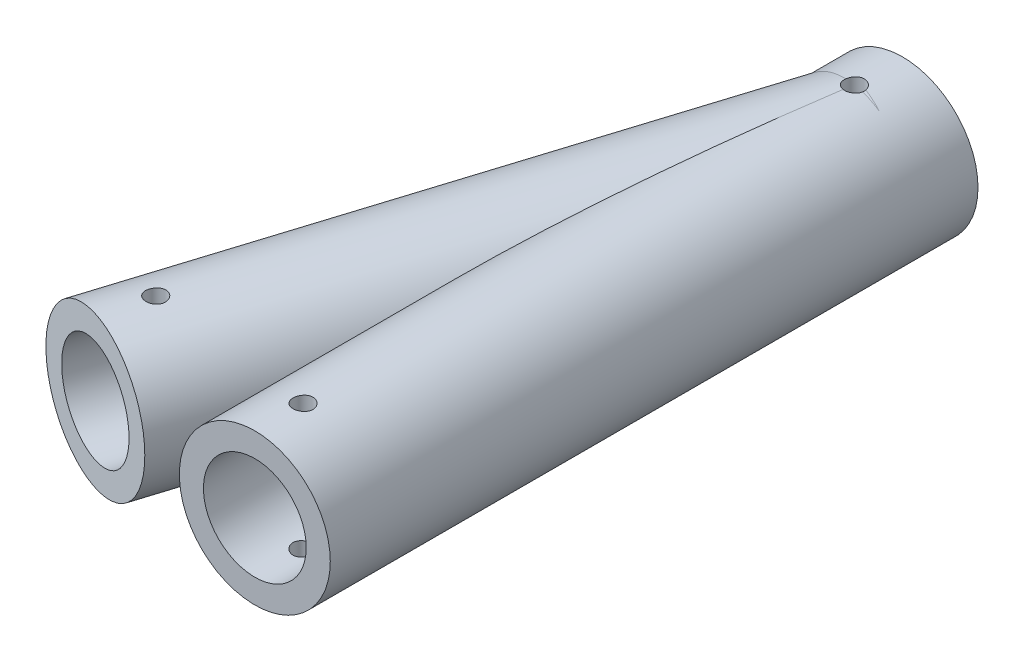
from build123d import *

# Parameters (mm, degrees)
SKETCH1_R                = 23.5
SKETCH1_R_2              = 16
BOSS_EXTRUDE1_DEPTH      = 111.7
BOSS_EXTRUDE1_DEPTH_BACK = 90
SKETCH4_R                = 23.5
SKETCH4_R_2              = 16
BOSS_EXTRUDE2_DEPTH      = 110
BOSS_EXTRUDE2_DEPTH_BACK = 80
SKETCH5_R                = 16
CUT_EXTRUDE1_DEPTH       = 202.993894755
SKETCH7_R                = 3.1
CUT_EXTRUDE3_DEPTH       = 24.5
CUT_EXTRUDE3_DEPTH_BACK  = 24.5


with BuildPart() as part:
    # Sketch1 → Boss-Extrude1 (new body, two sides)
    with BuildSketch(Plane.XY) as boss_extrude1_sk:
        Circle(SKETCH1_R)
        Circle(SKETCH1_R_2, mode=Mode.SUBTRACT)
    extrude(amount=BOSS_EXTRUDE1_DEPTH)
    extrude(boss_extrude1_sk.sketch, amount=-BOSS_EXTRUDE1_DEPTH_BACK)

    # Sketch4 → Boss-Extrude2 (add, two sides)
    with BuildSketch(Plane(origin=(-2.101496793, 0, 6.70588442), x_dir=(0, -1, 0), z_dir=(-0.299040792, 0, 0.954240329))) as boss_extrude2_sk:
        with Locations((0, -22.42464772)):
            Circle(SKETCH4_R)
        with Locations((0, -22.42464772)):
            Circle(SKETCH4_R_2, mode=Mode.SUBTRACT)
    extrude(amount=BOSS_EXTRUDE2_DEPTH)
    extrude(boss_extrude2_sk.sketch, amount=-BOSS_EXTRUDE2_DEPTH_BACK)

    # Sketch5 → Cut-Extrude1 (cut, through all)
    with BuildSketch(Plane(origin=(0, 0, -90), x_dir=(-1, 0, 0), z_dir=(0, 0, -1))):
        Circle(SKETCH5_R)
    extrude(amount=-CUT_EXTRUDE1_DEPTH, mode=Mode.SUBTRACT)

    # Sketch7 → Cut-Extrude3 (cut, two sides)
    with BuildSketch(Plane(origin=(0, 0, 0), x_dir=(1, 0, 0), z_dir=(0, 1, 0))) as cut_extrude3_sk:
        with Locations((0, -96.7)):
            Circle(SKETCH7_R)
        with Locations((0, 75)):
            Circle(SKETCH7_R)
        with Locations((-51.908875264, -90.652831209)):
            Circle(SKETCH7_R)
    extrude(amount=CUT_EXTRUDE3_DEPTH, mode=Mode.SUBTRACT)
    extrude(cut_extrude3_sk.sketch, amount=-CUT_EXTRUDE3_DEPTH_BACK, mode=Mode.SUBTRACT)


solid = part.part
